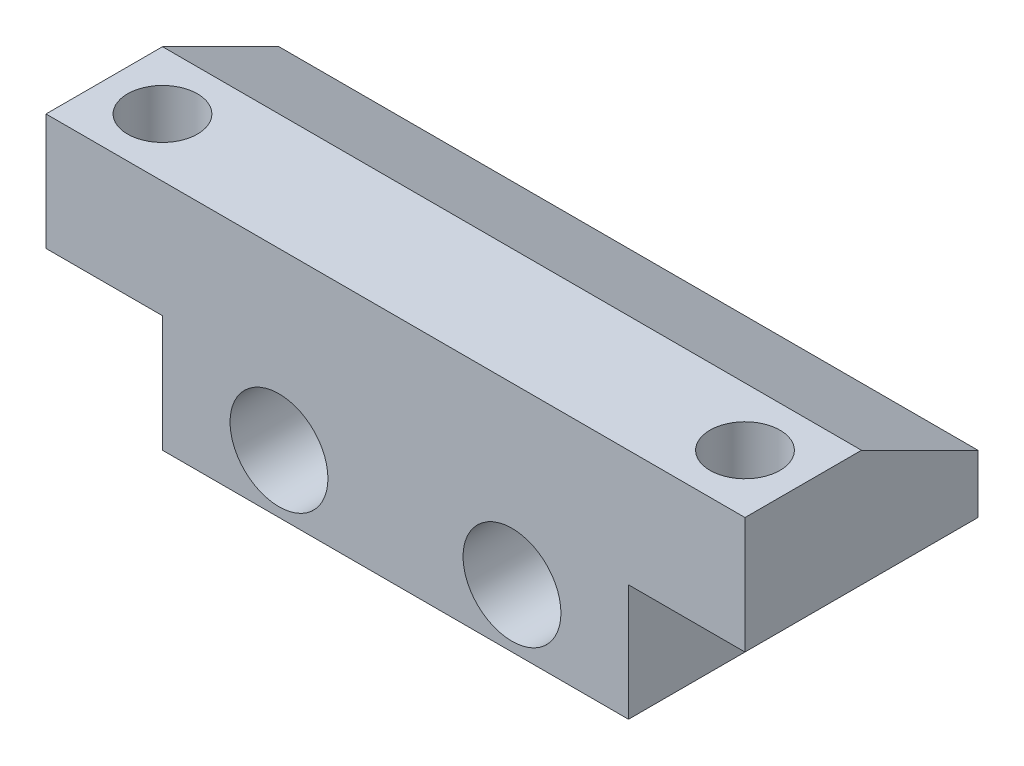
from build123d import *

# Parameters (mm, degrees)
SKETCH1_W           = 30
SKETCH1_H           = 10
BOSS_EXTRUDE1_DEPTH = 5
SKETCH2_W           = 20
SKETCH2_H           = 10
BOSS_EXTRUDE2_DEPTH = 5
SKETCH3_R           = 2.1
CUT_EXTRUDE1_DEPTH  = 10
LPATTERN1_COUNT     = 2
LPATTERN1_PITCH     = 10
SKETCH4_R           = 1.5
CUT_EXTRUDE2_DEPTH  = 5
LPATTERN2_COUNT     = 2
LPATTERN2_PITCH     = 25
SKETCH5_W           = 1.5
SKETCH5_H           = 1.5
CUT_EXTRUDE3_DEPTH  = 5
CHAMFER1_SIZE       = 2.5
CHAMFER1_SIZE2      = 5


with BuildPart() as part:
    # Sketch1 → Boss-Extrude1 (new body)
    with BuildSketch(Plane(origin=(0, 0, 0), x_dir=(1, 0, 0), z_dir=(0, 1, 0))):
        with Locations((15, 5)):
            Rectangle(SKETCH1_W, SKETCH1_H)
    extrude(amount=BOSS_EXTRUDE1_DEPTH)

    # Sketch2 → Boss-Extrude2 (add)
    with BuildSketch(Plane.XZ):
        with Locations((15, -5)):
            Rectangle(SKETCH2_W, SKETCH2_H)
    extrude(amount=BOSS_EXTRUDE2_DEPTH)

    # Sketch3 → Cut-Extrude1 (cut)
    with BuildSketch(Plane.XY):
        with Locations((20, -2.5)):
            Circle(SKETCH3_R)
    cut_extrude1 = extrude(amount=-CUT_EXTRUDE1_DEPTH, mode=Mode.SUBTRACT)

    # LPattern1: Cut-Extrude1 ×2
    with Locations(*[(-i * LPATTERN1_PITCH, 0, 0) for i in range(1, LPATTERN1_COUNT)]):
        add(cut_extrude1, mode=Mode.SUBTRACT)

    # Sketch4 → Cut-Extrude2 (cut)
    with BuildSketch(Plane(origin=(0, 5, 0), x_dir=(1, 0, 0), z_dir=(0, 1, 0))):
        with Locations((27.5, 2.5)):
            Circle(SKETCH4_R)
    cut_extrude2 = extrude(amount=-CUT_EXTRUDE2_DEPTH, mode=Mode.SUBTRACT)

    # LPattern2: Cut-Extrude2 ×2
    with Locations(*[(-i * LPATTERN2_PITCH, 0, 0) for i in range(1, LPATTERN2_COUNT)]):
        add(cut_extrude2, mode=Mode.SUBTRACT)

    # Sketch5 → Cut-Extrude3 (cut)
    with BuildSketch(Plane.XZ.offset(5)):
        with Locations((15, -9.25)):
            Rectangle(SKETCH5_W, SKETCH5_H)
    extrude(amount=-CUT_EXTRUDE3_DEPTH, mode=Mode.SUBTRACT)

    # Chamfer1
    chamfer1_edges = [part.edges().sort_by_distance(p)[0] for p in [
        (15, 5, -10),
    ]]
    chamfer1_side = [part.faces().sort_by_distance(p)[0] for p in [
        (15, 0.991763931, -10),
    ]]
    chamfer(chamfer1_edges, length=CHAMFER1_SIZE, length2=CHAMFER1_SIZE2, reference=chamfer1_side[0])


solid = part.part
